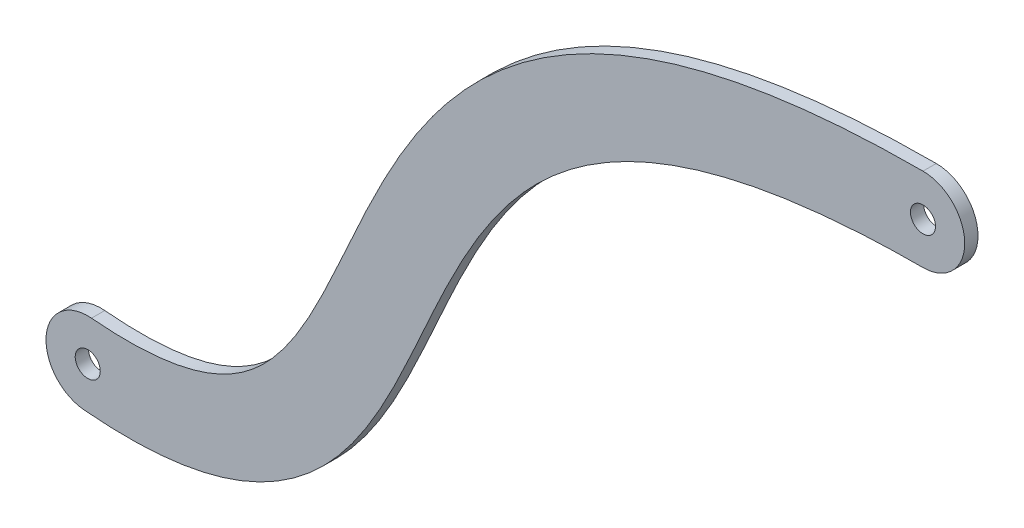
from build123d import *

# Parameters (mm, degrees)
SKETCH2_R           = 3
BOSS_EXTRUDE1_DEPTH = 3.175


with BuildPart() as part:
    # Sketch2 → Boss-Extrude1 (new body)
    with BuildSketch(Plane.XY):
        with BuildLine():
            ThreePointArc((0, 10), (10, 0), (0, -10))
            add(Edge.make_bspline(
                [(0, -10), (-1.251020864, -10), (-3.774820805, -10.016454286), (-8.647714228, -10.113882577), (-14.535295335, -10.354194809), (-21.245865223, -10.824273004), (-29.746585805, -11.682556581), (-39.552493021, -13.169090017), (-50.089820276, -15.548726183), (-59.483660199, -18.458255584), (-70.610237991, -22.961745838), (-82.148564476, -29.615471875), (-93.054010705, -38.911736434), (-101.785405177, -49.341668998), (-108.943514578, -60.724171124), (-115.045937004, -72.782876008), (-120.624536438, -85.169554655), (-126.276327656, -97.517742627), (-132.698495585, -109.461640853), (-140.721639832, -120.579621109), (-149.489597914, -128.565293962), (-157.988102873, -133.649852232), (-165.090036196, -136.691162647), (-172.903862455, -138.88370963), (-180.005628003, -139.974310929), (-186.058063141, -140.398698048), (-190.788685764, -140.492078653), (-194.902893505, -140.380838582), (-198.289956322, -140.178624717), (-200.037485643, -140.037656252), (-200.903383383, -139.959111329)],
                knots=[0, 0, 0, 0, 0.0078125, 0.015625, 0.03125, 0.046875, 0.0625, 0.09375, 0.125, 0.15625, 0.1875, 0.25, 0.3125, 0.375, 0.4375, 0.5, 0.5625, 0.625, 0.6875, 0.75, 0.8125, 0.84375, 0.875, 0.90625, 0.9375, 0.953125, 0.96875, 0.984375, 0.9921875, 1, 1, 1, 1], degree=3))
            ThreePointArc((-200.903383383, -139.959111329), (-209.959111329, -129.096616617), (-199.096616617, -120.040888671))
            add(Edge.make_bspline(
                [(0, 10), (-1.338896135, 10), (-4.036631282, 9.982420404), (-9.271872007, 9.877844261), (-15.629863548, 9.618642545), (-22.936639656, 9.107283685), (-32.273749385, 8.165214939), (-43.203125935, 6.512222832), (-55.204214548, 3.807437165), (-66.155402215, 0.421098599), (-79.433418064, -4.944436555), (-93.675561018, -13.127882389), (-107.358604539, -24.79328789), (-118.079923605, -37.63772884), (-126.451066369, -50.997943321), (-133.166744909, -64.305937773), (-138.9074066, -77.065580836), (-144.288347953, -88.798976567), (-149.824694436, -99.027563746), (-155.898160469, -107.328609975), (-161.669374507, -112.527277269), (-167.083581014, -115.769099962), (-171.708355928, -117.756489287), (-177.065159674, -119.270992126), (-182.267818177, -120.080328974), (-186.933490647, -120.409425438), (-190.69395485, -120.485068399), (-194.061150572, -120.394947781), (-196.883542888, -120.226727877), (-198.36544529, -120.107212664), (-199.096616617, -120.040888671)],
                knots=[0, 0, 0, 0, 0.0078125, 0.015625, 0.03125, 0.046875, 0.0625, 0.09375, 0.125, 0.15625, 0.1875, 0.25, 0.3125, 0.375, 0.4375, 0.5, 0.5625, 0.625, 0.6875, 0.75, 0.8125, 0.84375, 0.875, 0.90625, 0.9375, 0.953125, 0.96875, 0.984375, 0.9921875, 1, 1, 1, 1], degree=3))
        make_face()
        Circle(SKETCH2_R, mode=Mode.SUBTRACT)
        with Locations((-200, -130)):
            Circle(SKETCH2_R, mode=Mode.SUBTRACT)
    extrude(amount=BOSS_EXTRUDE1_DEPTH)


solid = part.part
